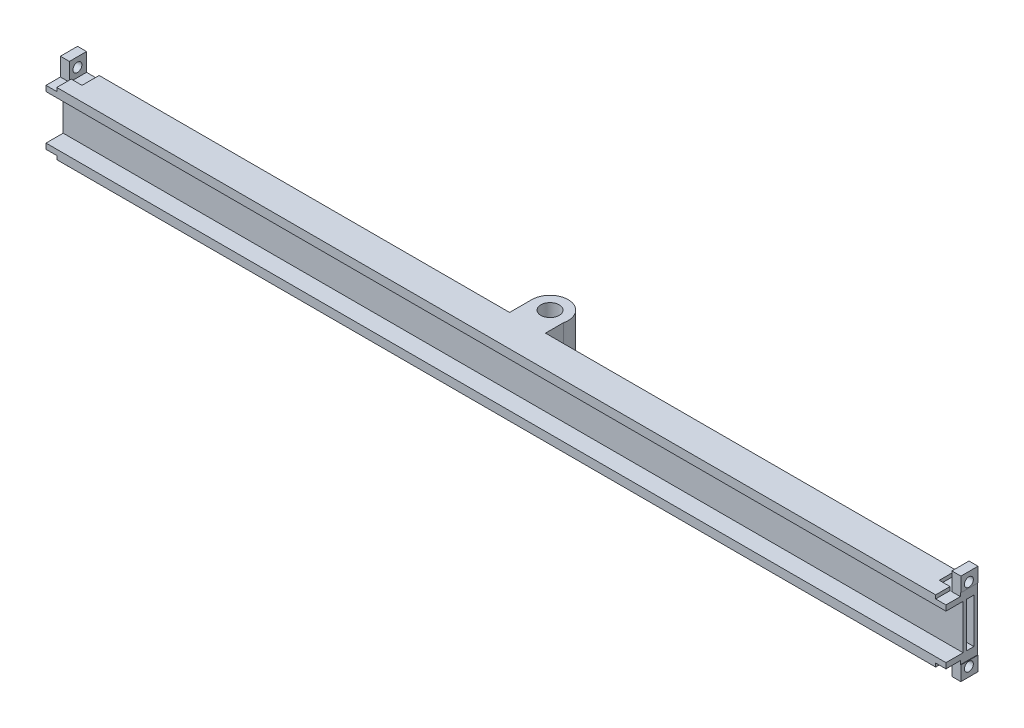
from build123d import *

# Parameters (mm, degrees)
BOSS_EXTRUDE1_DEPTH     = 250
SKETCH3_R               = 2.55
BOSS_EXTRUDE2_DEPTH     = 17.3825
SKETCH8_W               = 12.3825
SKETCH8_H               = 2
CUT_EXTRUDE4_DEPTH      = 251
SKETCH9_W               = 2
SKETCH9_H               = 12.3825
CUT_EXTRUDE5_DEPTH      = 1
SKETCH10_W              = 2.5
SKETCH10_H              = 4.00875
BOSS_EXTRUDE3_DEPTH     = 8.7625
SKETCH11_R              = 1.25
CUT_EXTRUDE6_DEPTH      = 247.638802
SKETCH14_W              = 3
SKETCH14_H              = 5
CUT_EXTRUDE7_DEPTH      = 4
SKETCH15_W              = 3.5
SKETCH15_H              = 4.7625
CUT_EXTRUDE9_DEPTH      = 1
MIRROR8_COPY_1_SKETCH_W = 3.5
MIRROR8_COPY_1_SKETCH_H = 4.7625
MIRROR8_COPY_1_DEPTH    = 1


with BuildPart() as part:
    # Sketch1 → Boss-Extrude1 (new body)
    with BuildSketch(Plane.YZ):
        Polygon((0, 4.7625), (-2.5, 4.7625), (-2.5, -4), (14.8825, -4), (14.8825, 4.7625), (12.3825, 4.7625), (12.3825, 0), (0, 0), align=None)
    extrude(amount=BOSS_EXTRUDE1_DEPTH)

    # Sketch3 → Boss-Extrude2 (add)
    with BuildSketch(Plane.XZ.offset(2.5)):
        with BuildLine():
            Line((120.019401026, -4), (129.980598974, -4))
            Line((129.980598974, -4), (129.980598974, -9))
            ThreePointArc((129.980598974, -9), (125.66141047, -15.191034327), (120.019401026, -10.175854887))
            Line((120.019401026, -10.175854887), (120.019401026, -4))
        make_face()
        with Locations((125.069401026, -10.175854887)):
            Circle(SKETCH3_R, mode=Mode.SUBTRACT)
    extrude(amount=-BOSS_EXTRUDE2_DEPTH)

    # Sketch8 → Cut-Extrude4 (cut, through all)
    with BuildSketch(Plane.YZ.offset(250)):
        with Locations((6.19125, -2)):
            Rectangle(SKETCH8_W, SKETCH8_H)
    extrude(amount=-CUT_EXTRUDE4_DEPTH, mode=Mode.SUBTRACT)

    # Sketch9 → Cut-Extrude5 (cut)
    with BuildSketch(Plane(origin=(0, 0, -4), x_dir=(-1, 0, 0), z_dir=(0, 0, -1))):
        with Locations((-117.519401026, 6.19125)):
            Rectangle(SKETCH9_W, SKETCH9_H)
    cut_extrude5 = extrude(amount=-CUT_EXTRUDE5_DEPTH, mode=Mode.SUBTRACT)

    # Mirror1: Cut-Extrude5 across plane
    add(cut_extrude5.mirror(Plane.ZY.offset(-125.069401026)), mode=Mode.SUBTRACT)

    # Sketch10 → Boss-Extrude3 (add)
    with BuildSketch(Plane.XY.offset(4.7625)):
        with Locations((1.25, 16.886875)):
            Rectangle(SKETCH10_W, SKETCH10_H)
        with Locations((1.25, -4.504375)):
            Rectangle(SKETCH10_W, SKETCH10_H)
    boss_extrude3 = extrude(amount=-BOSS_EXTRUDE3_DEPTH)

    # Mirror2: Boss-Extrude3 across plane
    add(boss_extrude3.mirror(Plane.ZY.offset(-125.069401026)))

    # Sketch11 → Cut-Extrude6 (cut)
    with BuildSketch(Plane.YZ.offset(250.138802052)):
        with Locations((16.35125, -1.46)):
            Circle(SKETCH11_R)
        with Locations((-3.96875, -1.46)):
            Circle(SKETCH11_R)
    cut_extrude6 = extrude(amount=-CUT_EXTRUDE6_DEPTH, mode=Mode.SUBTRACT)

    # Mirror3: Cut-Extrude6 across plane
    add(cut_extrude6.mirror(Plane.ZY.offset(-125.069401026)), mode=Mode.SUBTRACT)

    # Sketch14 → Cut-Extrude7 (cut)
    with BuildSketch(Plane.XY.offset(4.7625)):
        with Locations((1.5, -4.00875)):
            Rectangle(SKETCH14_W, SKETCH14_H)
        with Locations((1.5, 16.39125)):
            Rectangle(SKETCH14_W, SKETCH14_H)
    cut_extrude7 = extrude(amount=-CUT_EXTRUDE7_DEPTH, mode=Mode.SUBTRACT)

    # Mirror4: Cut-Extrude7 across plane
    add(cut_extrude7.mirror(Plane.ZY.offset(-125.069401026)), mode=Mode.SUBTRACT)

    # Sketch15 → Cut-Extrude9 (cut)
    with BuildSketch(Plane(origin=(0, -2.5, 0), x_dir=(-1, 0, 0), z_dir=(0, -1, 0))):
        with Locations((-4.25, 1.61875)):
            Rectangle(SKETCH15_W, SKETCH15_H)
    cut_extrude9 = extrude(amount=-CUT_EXTRUDE9_DEPTH, mode=Mode.SUBTRACT)

    # Mirror7: Cut-Extrude9 across plane
    add(cut_extrude9.mirror(Plane.ZX.offset(6.19125)), mode=Mode.SUBTRACT)

    # Mirror8: Cut-Extrude9 across plane
    add(cut_extrude9.mirror(Plane.ZY.offset(-125.069401026)), mode=Mode.SUBTRACT)

    # Mirror8 copy 1 sketch → Mirror8 copy 1 (cut)
    with BuildSketch(Plane(origin=(250.138802052, 14.8825, 0), x_dir=(1, 0, 0), z_dir=(0, 1, 0))):
        with Locations((-4.25, 1.61875)):
            Rectangle(MIRROR8_COPY_1_SKETCH_W, MIRROR8_COPY_1_SKETCH_H)
    extrude(amount=-MIRROR8_COPY_1_DEPTH, mode=Mode.SUBTRACT)


solid = part.part
